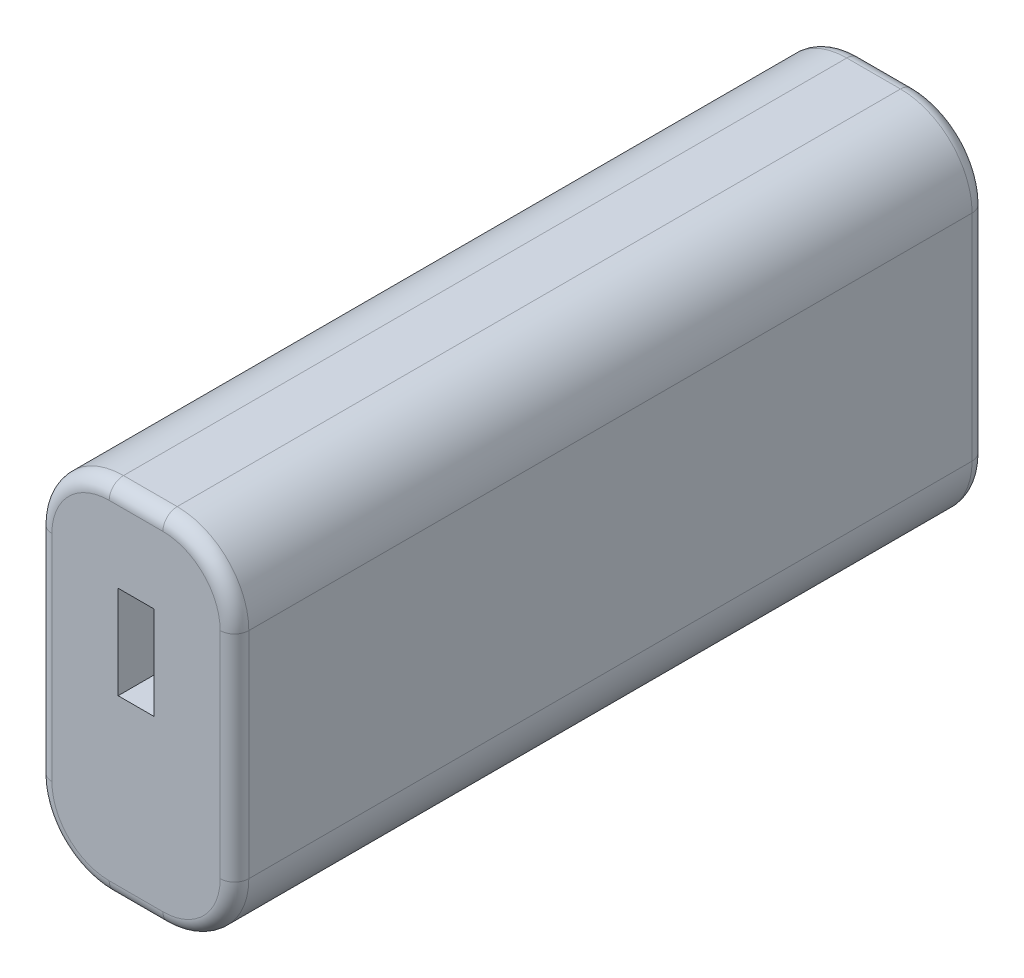
from build123d import *

# Parameters (mm, degrees)
BOSS_EXTRUDE1_DEPTH = 105
FILLET1_R           = 2
CUT_EXTRUDE1_DEPTH  = 20


with BuildPart() as part:
    # Sketch1 → Boss-Extrude1 (new body)
    with BuildSketch(Plane.XY):
        with BuildLine():
            Line((0, 10), (0, 40))
            ThreePointArc((0, 40), (2.928932188, 47.071067812), (10, 50))
            Line((10, 50), (17.5, 50))
            ThreePointArc((17.5, 50), (24.571067812, 47.071067812), (27.5, 40))
            Line((27.5, 40), (27.5, 10))
            ThreePointArc((27.5, 10), (24.571067812, 2.928932188), (17.5, 0))
            Line((17.5, 0), (10, 0))
            ThreePointArc((10, 0), (2.928932188, 2.928932188), (0, 10))
        make_face()
    extrude(amount=BOSS_EXTRUDE1_DEPTH)

    # Fillet1
    fillet1_edges = [part.edges().sort_by_distance(p)[0] for p in [
        (13.75, 50, 0),
        (24.571067812, 47.071067812, 0),
        (27.5, 25, 0),
        (24.571067812, 2.928932188, 0),
        (24.571067812, 47.071067812, 105),
        (13.75, 50, 105),
        (2.928932188, 47.071067812, 105),
        (0, 25, 105),
        (2.928932188, 2.928932188, 105),
        (13.75, 0, 105),
        (24.571067812, 2.928932188, 105),
        (13.75, 0, 0),
        (27.5, 25, 105),
        (2.928932188, 2.928932188, 0),
        (0, 25, 0),
        (2.928932188, 47.071067812, 0),
    ]]
    fillet(fillet1_edges, radius=FILLET1_R)

    # Sketch2 → Cut-Extrude1 (cut)
    with BuildSketch(Plane.XY.offset(105)):
        Polygon((13.75, 38), (11.25, 38), (11.25, 25), (16.25, 25), (16.25, 38), align=None)
    extrude(amount=-CUT_EXTRUDE1_DEPTH, mode=Mode.SUBTRACT)


solid = part.part
